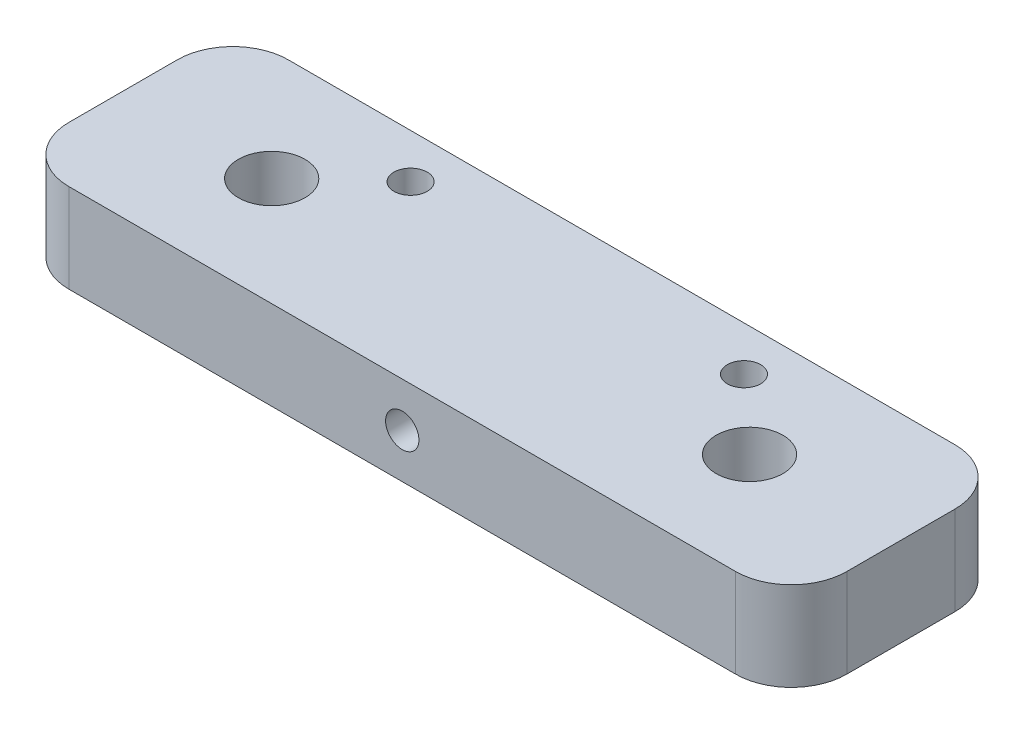
from build123d import *

# Parameters (mm, degrees)
SKETCH_1_W          = 70
SKETCH_1_H          = 19.75
EXTRUDE_1_DEPTH     = 8
SKETCH_2_R          = 3
CUT_EXTRUDE_1_DEPTH = 9
SKETCH_9_R          = 1.5
CUT_EXTRUDE_7_DEPTH = 9
SKETCH_10_R         = 1.5
CUT_EXTRUDE_8_DEPTH = 20.75
FILLET_1_R          = 5
SKETCH_11_R         = 3.5
CUT_EXTRUDE_9_DEPTH = 2


with BuildPart() as part:
    # 草图1 → 凸台-拉伸1 (new body)
    with BuildSketch(Plane(origin=(0, 0, 0), x_dir=(1, 0, 0), z_dir=(0, 1, 0))):
        Rectangle(SKETCH_1_W, SKETCH_1_H)
    extrude(amount=EXTRUDE_1_DEPTH)

    # 草图2 → 切除-拉伸1 (cut, through all)
    with BuildSketch(Plane(origin=(0, 8, 0), x_dir=(1, 0, 0), z_dir=(0, 1, 0))):
        with Locations((-21.5, -0.125)):
            Circle(SKETCH_2_R)
        with Locations((21.5, -0.125)):
            Circle(SKETCH_2_R)
    extrude(amount=-CUT_EXTRUDE_1_DEPTH, mode=Mode.SUBTRACT)

    # 草图9 → 切除-拉伸7 (cut, through all)
    with BuildSketch(Plane(origin=(0, 8, 0), x_dir=(1, 0, 0), z_dir=(0, 1, 0))):
        with Locations((-15, 5.875)):
            Circle(SKETCH_9_R)
        with Locations((15, 5.875)):
            Circle(SKETCH_9_R)
    extrude(amount=-CUT_EXTRUDE_7_DEPTH, mode=Mode.SUBTRACT)

    # 草图10 → 切除-拉伸8 (cut, through all)
    with BuildSketch(Plane(origin=(0, 0, -9.875), x_dir=(-1, 0, 0), z_dir=(0, 0, -1))):
        with Locations((0, 4)):
            Circle(SKETCH_10_R)
    extrude(amount=-CUT_EXTRUDE_8_DEPTH, mode=Mode.SUBTRACT)

    # 圆角1
    fillet_1_edges = [part.edges().sort_by_distance(p)[0] for p in [
        (35, 4, 9.875),
        (-35, 4, 9.875),
        (-35, 4, -9.875),
        (35, 4, -9.875),
    ]]
    fillet(fillet_1_edges, radius=FILLET_1_R)

    # 草图11 → 切除-拉伸9 (cut)
    with BuildSketch(Plane(origin=(0, 0, -9.875), x_dir=(-1, 0, 0), z_dir=(0, 0, -1))):
        with Locations((0, 4)):
            Circle(SKETCH_11_R)
    extrude(amount=-CUT_EXTRUDE_9_DEPTH, mode=Mode.SUBTRACT)


solid = part.part
